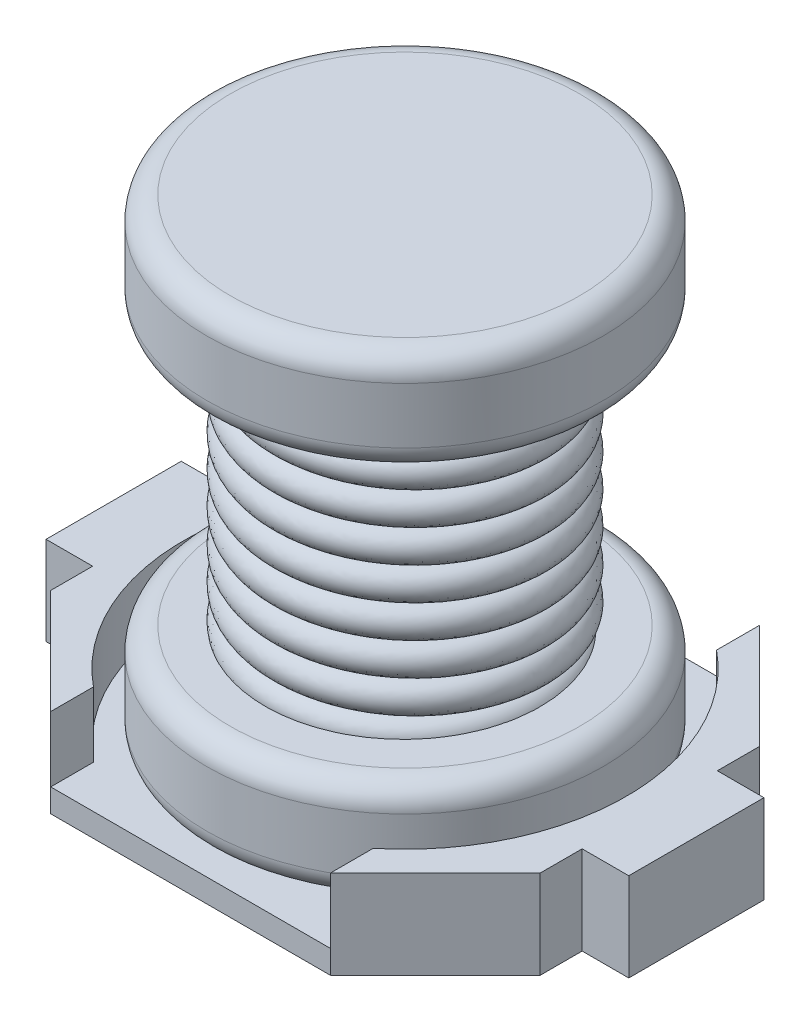
from build123d import *

# Parameters (mm, degrees)
CROQUIS1_W            = 10.5
CROQUIS1_H            = 9.2
EXTRUIR1_DEPTH        = 1.9
CROQUIS2_W            = 6
CROQUIS2_H            = 1.4
CORTAR_EXTRUIR1_DEPTH = 13.9
CROQUIS3_W            = 1
CROQUIS3_H            = 2.9
EXTRUIR2_DEPTH        = 1.9
CORTAR_EXTRUIR2_DEPTH = 4.9
CROQUIS5_R            = 4.75
CORTAR_EXTRUIR4_DEPTH = 4.9
BARRER1_PITCH         = 0.7
BARRER1_HEIGHT        = 5.6
BARRER1_RADIUS        = 2.75900428
BARRER1_START_ANGLE   = -180
CROQUIS8_R            = 0.342126569
REDONDEO1_R           = 0.5


with BuildPart() as part:
    # Croquis1 → Extruir1 (new body)
    with BuildSketch(Plane(origin=(0, 0, 0), x_dir=(1, 0, 0), z_dir=(0, 1, 0))):
        Rectangle(CROQUIS1_W, CROQUIS1_H)
    extrude(amount=EXTRUIR1_DEPTH)

    # Croquis2 → Cortar-Extruir1 (cut)
    with BuildSketch(Plane.XY.offset(4.6)):
        with Locations((0, 1.2)):
            Rectangle(CROQUIS2_W, CROQUIS2_H)
    extrude(amount=-CORTAR_EXTRUIR1_DEPTH, mode=Mode.SUBTRACT)

    # Croquis3 → Extruir2 (add)
    with BuildSketch(Plane(origin=(0, 1.9, 0), x_dir=(1, 0, 0), z_dir=(0, 1, 0))):
        with Locations((5.75, 0)):
            Rectangle(CROQUIS3_W, CROQUIS3_H)
        with Locations((-5.75, 0)):
            Rectangle(CROQUIS3_W, CROQUIS3_H)
    extrude(amount=-EXTRUIR2_DEPTH)

    # Croquis4 → Cortar-Extruir2 (cut)
    with BuildSketch(Plane(origin=(0, 1.9, 0), x_dir=(1, 0, 0), z_dir=(0, 1, 0))):
        Polygon((-3, 4.6), (-5.25, 2.35), (-6.161497734, 2.35), (-6.161497734, 5.064836166), (-3, 5.064836166), align=None)
        Polygon((3, 5.064836166), (3, 4.6), (5.25, 2.35), (6.161497734, 2.35), (6.161497734, 5.064836166), align=None)
        Polygon((3, -4.6), (5.25, -2.35), (6.161497734, -2.35), (6.161497734, -5.064836166), (3, -5.064836166), align=None)
        Polygon((-3, -5.064836166), (-3, -4.6), (-5.25, -2.35), (-6.161497734, -2.35), (-6.161497734, -5.064836166), align=None)
    extrude(amount=-CORTAR_EXTRUIR2_DEPTH, mode=Mode.SUBTRACT)

    # Croquis5 → Cortar-Extruir4 (cut)
    with BuildSketch(Plane(origin=(0, 0.5, 0), x_dir=(1, 0, 0), z_dir=(0, 1, 0))):
        Circle(CROQUIS5_R)
    extrude(amount=CORTAR_EXTRUIR4_DEPTH, mode=Mode.SUBTRACT)


with BuildPart() as body_2:
    # Croquis6 → Revolución1 (revolve)
    with BuildSketch(Plane(origin=(0, 0, 0), x_dir=(0, 0, -1), z_dir=(1, 0, 0))):
        Polygon((0, 0.5), (0, 10.7), (4.25, 10.7), (4.25, 8.5), (2.25, 8.5), (2.25, 2.7), (4.25, 2.7), (4.25, 0.5), align=None)
    revolve(axis=Axis((0, 0.5, 0), (0, -1, 0)))

    # Redondeo1
    redondeo1_edges = [body_2.edges().sort_by_distance(p)[0] for p in [
        (0, 10.7, 4.25),
        (0, 8.5, 4.25),
        (0, 2.7, 4.25),
        (0, 0.5, 4.25),
    ]]
    fillet(redondeo1_edges, radius=REDONDEO1_R)


with BuildPart() as body_3:
    # Barrer1: sweep along a helix
    with BuildLine() as barrer1_path:
        add(Helix(BARRER1_PITCH, BARRER1_HEIGHT, BARRER1_RADIUS, center=(0, 2.7, 0), direction=(0, 1, 0), lefthand=True, mode=Mode.PRIVATE).rotate(Axis((0, 2.7, 0), (0, 1, 0)), BARRER1_START_ANGLE))
    # Croquis8 → Barrer1 (sweep)
    with BuildSketch(Plane(origin=(0, 0, 0), x_dir=(0, 0, -1), z_dir=(1, 0, 0))):
        with Locations((2.661711681, 3.05996706)):
            Circle(CROQUIS8_R)
    sweep(path=barrer1_path.line, is_frenet=True)


solid = Compound([part.part, body_2.part, body_3.part])
